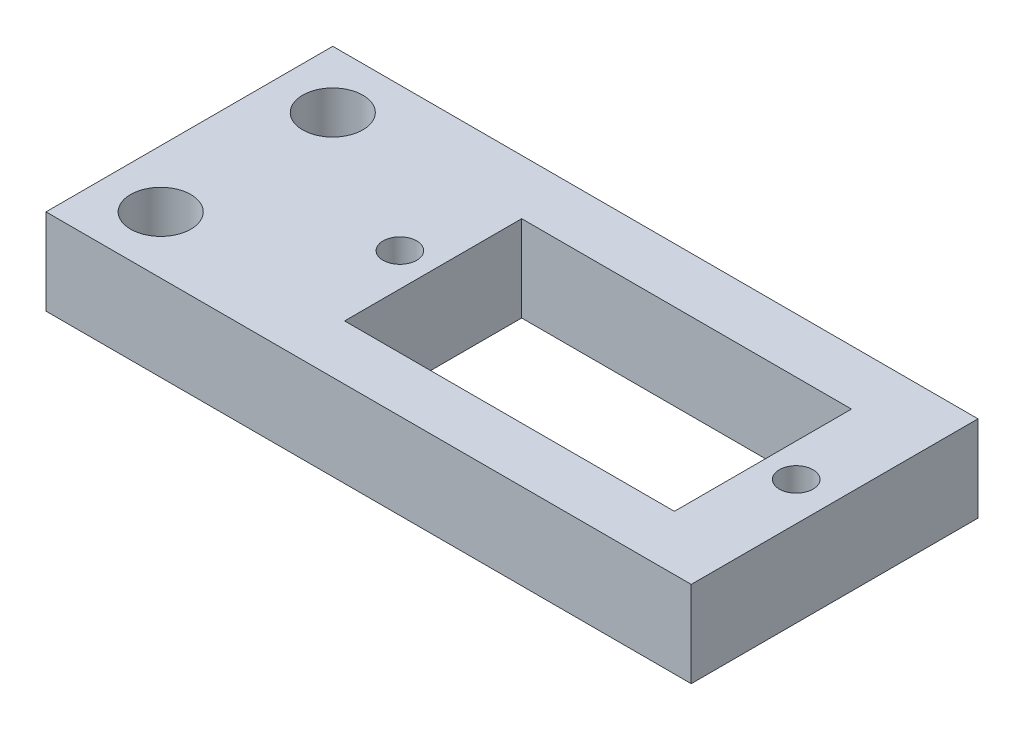
from build123d import *

# Parameters (mm, degrees)
SKETCH1_W           = 45
SKETCH1_H           = 20
BOSS_EXTRUDE1_DEPTH = 6
SKETCH2_R           = 2.1
CUT_EXTRUDE1_DEPTH  = 6
SKETCH3_R           = 1.175
SKETCH3_W           = 23
SKETCH3_H           = 12.35
CUT_EXTRUDE2_DEPTH  = 6


with BuildPart() as part:
    # Sketch1 → Boss-Extrude1 (new body)
    with BuildSketch(Plane(origin=(0, 0, 0), x_dir=(1, 0, 0), z_dir=(0, 1, 0))):
        Rectangle(SKETCH1_W, SKETCH1_H)
    extrude(amount=BOSS_EXTRUDE1_DEPTH)

    # Sketch2 → Cut-Extrude1 (cut)
    with BuildSketch(Plane(origin=(0, 6, 0), x_dir=(1, 0, 0), z_dir=(0, 1, 0))):
        with Locations((-18.5, -6)):
            Circle(SKETCH2_R)
        with Locations((-18.5, 6)):
            Circle(SKETCH2_R)
    extrude(amount=-CUT_EXTRUDE1_DEPTH, mode=Mode.SUBTRACT)

    # Sketch3 → Cut-Extrude2 (cut)
    with BuildSketch(Plane(origin=(0, 6, 0), x_dir=(1, 0, 0), z_dir=(0, 1, 0))):
        with Locations((-7.82, 0)):
            Circle(SKETCH3_R)
        with Locations((19.82, 0)):
            Circle(SKETCH3_R)
        with Locations((6, 0)):
            Rectangle(SKETCH3_W, SKETCH3_H)
    extrude(amount=-CUT_EXTRUDE2_DEPTH, mode=Mode.SUBTRACT)


solid = part.part
